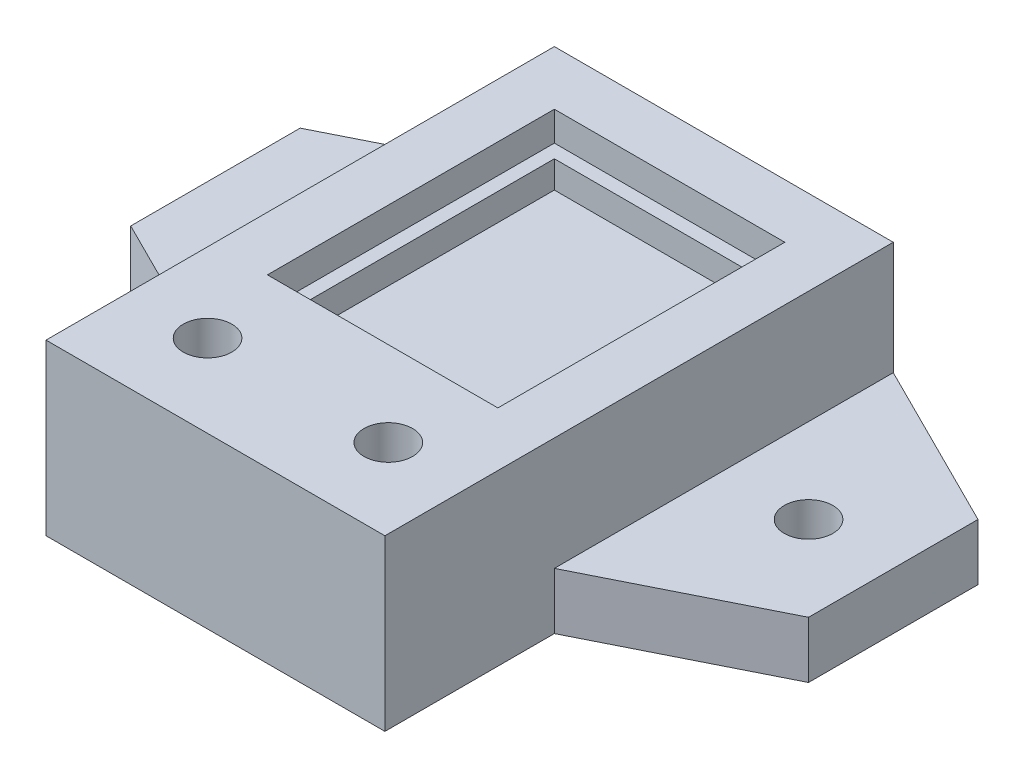
from build123d import *

# Parameters (mm, degrees)
SKETCH1_W                = 30
SKETCH1_H                = 30
BOSS_EXTRUDE1_DEPTH      = 5
M4_CLEARANCE_HOLE1_D     = 4.3
M4_CLEARANCE_HOLE1_DEPTH = 5
SKETCH13_W               = 30
SKETCH13_H               = 45
BOSS_EXTRUDE7_DEPTH      = 15
SKETCH14_W               = 20.4
SKETCH14_H               = 25.4
CUT_EXTRUDE2_DEPTH       = 5
BOSS_EXTRUDE8_REACH      = 19.6
BOSS_EXTRUDE8_START      = -2.6
SKETCH15_W               = 20.4
SKETCH15_H               = 25.4
SKETCH15_W_2             = 18
SKETCH15_H_2             = 23
M4_CLEARANCE_HOLE2_D     = 4.3
M4_CLEARANCE_HOLE2_DEPTH = 15
CUT_EXTRUDE1_DEPTH       = 5


with BuildPart() as part:
    # Sketch1 → Boss-Extrude1 (new body)
    with BuildSketch(Plane(origin=(0, 0, 0), x_dir=(1, 0, 0), z_dir=(0, 1, 0))):
        Polygon((15, 22.5), (15, -7.5), (0, 0), (0, 15), align=None)
        with Locations((30, 7.5)):
            Rectangle(SKETCH1_W, SKETCH1_H)
        Polygon((45, -7.5), (45, 22.5), (60, 15), (60, 0), align=None)
    extrude(amount=BOSS_EXTRUDE1_DEPTH)

    # M4 Clearance Hole1
    with Locations(Plane(origin=(0, 0, 0), x_dir=(-1, 0, 0), z_dir=(0, -1, 0))):
        with Locations((-7.5, 7.5), (-52.5, 7.5)):
            Hole(M4_CLEARANCE_HOLE1_D / 2, depth=M4_CLEARANCE_HOLE1_DEPTH)

    # Sketch13 → Boss-Extrude7 (add)
    with BuildSketch(Plane(origin=(0, 0, 0), x_dir=(1, 0, 0), z_dir=(0, 1, 0))):
        with Locations((30, 0)):
            Rectangle(SKETCH13_W, SKETCH13_H)
    extrude(amount=BOSS_EXTRUDE7_DEPTH)

    # Sketch14 → Cut-Extrude2 (cut)
    with BuildSketch(Plane(origin=(0, 15, 0), x_dir=(1, 0, 0), z_dir=(0, 1, 0))):
        with Locations((30, 5)):
            Rectangle(SKETCH14_W, SKETCH14_H)
    extrude(amount=-CUT_EXTRUDE2_DEPTH, mode=Mode.SUBTRACT)

    # Sketch15 → Boss-Extrude8 (add, up to next)
    with BuildSketch(Plane(origin=(0, 15, 0), x_dir=(1, 0, 0), z_dir=(0, 1, 0)).offset(BOSS_EXTRUDE8_START), mode=Mode.PRIVATE) as boss_extrude8_sk1:
        with Locations((30, 5)):
            Rectangle(SKETCH15_W, SKETCH15_H)
        with Locations((30, 5)):
            Rectangle(SKETCH15_W_2, SKETCH15_H_2, mode=Mode.SUBTRACT)
    boss_extrude8_tool1 = extrude(boss_extrude8_sk1.sketch, amount=-BOSS_EXTRUDE8_REACH, mode=Mode.PRIVATE) - part.part
    add(boss_extrude8_tool1.solids().sort_by_distance((39.874221, 12.4, -5))[0])

    # M4 Clearance Hole2
    with Locations(Plane(origin=(0, 15, 0), x_dir=(1, 0, 0), z_dir=(0, 1, 0))):
        with Locations((22, -15.2), (38, -15.2)):
            Hole(M4_CLEARANCE_HOLE2_D / 2, depth=M4_CLEARANCE_HOLE2_DEPTH)

    # Sketch11 → Cut-Extrude1 (cut)
    with BuildSketch(Plane(origin=(0, 0, 0), x_dir=(-1, 0, 0), z_dir=(0, 1, 0))):
        Polygon((-22, 19.241451884), (-25.5, 17.220725942), (-25.5, 13.179274058), (-22, 11.158548116), (-18.5, 13.179274058), (-18.5, 17.220725942), align=None)
    cut_extrude1 = extrude(amount=CUT_EXTRUDE1_DEPTH, mode=Mode.SUBTRACT)

    # Mirror1: Cut-Extrude1 across plane
    add(cut_extrude1.mirror(Plane(origin=(30, 0, 0), x_dir=(0, 0, 1), z_dir=(1, 0, 0))), mode=Mode.SUBTRACT)


solid = part.part
